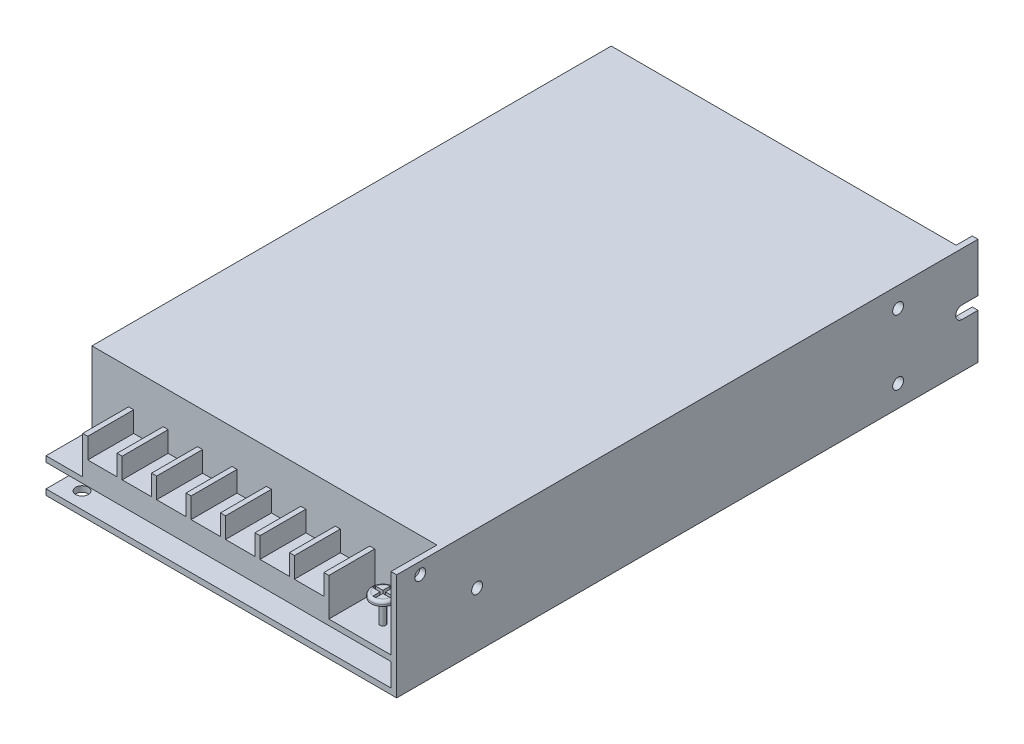
from build123d import *

# Parameters (mm, degrees)
SKETCH1_W           = 97
SKETCH1_H           = 29.491999944
BOSS_EXTRUDE1_DEPTH = 160.778000008
SKETCH2_W           = 95.4125
SKETCH2_H           = 6.35
CUT_EXTRUDE1_DEPTH  = 12.7
CUT_EXTRUDE2_DEPTH  = 19.967
SKETCH4_R           = 3.175
SKETCH4_R_2         = 0.79375
CUT_EXTRUDE3_DEPTH  = 6.35
FILLET1_R           = 0.79375
CUT_EXTRUDE4_DEPTH  = 1.27
SKETCH6_W           = 10.16
SKETCH6_H           = 27.904499944
CUT_EXTRUDE6_DEPTH  = 4.445
SKETCH7_R           = 1.5
CUT_EXTRUDE7_DEPTH  = 6.35
SKETCH8_R           = 1
SKETCH8_R_2         = 1.75
CUT_EXTRUDE8_DEPTH  = 6.35
CUT_EXTRUDE9_DEPTH  = 95.4125


with BuildPart() as part:
    # Sketch1 → Boss-Extrude1 (new body)
    with BuildSketch(Plane.XY):
        with Locations((48.5, 14.745999972)):
            Rectangle(SKETCH1_W, SKETCH1_H)
    extrude(amount=-BOSS_EXTRUDE1_DEPTH)

    # Sketch2 → Cut-Extrude1 (cut)
    with BuildSketch(Plane.XY):
        Polygon((95.4125, 9.525), (95.4125, 29.491999944), (0, 29.491999944), (0, 9.525), (10.16, 9.525), (10.16, 19.966999944), (11.557, 19.966999944), (11.557, 14.2875), (19.685, 14.2875), (19.685, 19.966999944), (21.082, 19.966999944), (21.082, 14.2875), (29.21, 14.2875), (29.21, 19.966999944), (30.607, 19.966999944), (30.607, 14.2875), (38.735, 14.2875), (38.735, 19.966999944), (40.132, 19.966999944), (40.132, 14.2875), (48.26, 14.2875), (48.26, 19.966999944), (49.657, 19.966999944), (49.657, 14.2875), (57.785, 14.2875), (57.785, 19.966999944), (59.182, 19.966999944), (59.182, 14.2875), (67.31, 14.2875), (67.31, 19.966999944), (68.707, 19.966999944), (68.707, 14.2875), (76.835, 14.2875), (76.835, 19.966999944), (78.232, 19.966999944), (78.232, 9.525), (83.64725, 9.525), (83.64725, 17.145), (89.99725, 17.145), (89.99725, 9.525), align=None)
        with Locations((47.70625, 4.7625)):
            Rectangle(SKETCH2_W, SKETCH2_H)
    extrude(amount=-CUT_EXTRUDE1_DEPTH, mode=Mode.SUBTRACT)

    # Sketch3 → Cut-Extrude2 (cut)
    with BuildSketch(Plane(origin=(0, 29.491999944, 0), x_dir=(1, 0, 0), z_dir=(0, 1, 0))):
        with BuildLine():
            ThreePointArc((89.99725, 6.35), (86.82225, 3.175), (83.64725, 6.35))
            Line((83.64725, 6.35), (83.64725, 0))
            Line((83.64725, 0), (89.99725, 0))
            Line((89.99725, 0), (89.99725, 6.35))
        make_face()
        with BuildLine():
            Line((89.99725, 12.7), (83.64725, 12.7))
            Line((83.64725, 12.7), (83.64725, 6.35))
            ThreePointArc((83.64725, 6.35), (86.82225, 9.525), (89.99725, 6.35))
            Line((89.99725, 6.35), (89.99725, 12.7))
        make_face()
    extrude(amount=-CUT_EXTRUDE2_DEPTH, mode=Mode.SUBTRACT)

    # Sketch4 → Cut-Extrude3 (cut)
    with BuildSketch(Plane(origin=(0, 9.525, 0), x_dir=(1, 0, 0), z_dir=(0, 1, 0))):
        with Locations((86.82225, 6.35)):
            Circle(SKETCH4_R)
        with Locations((86.82225, 6.35)):
            Circle(SKETCH4_R_2, mode=Mode.SUBTRACT)
    extrude(amount=CUT_EXTRUDE3_DEPTH, mode=Mode.SUBTRACT)

    # Fillet1
    fillet1_edges = [part.edges().sort_by_distance(p)[0] for p in [
        (83.64725, 17.145, -6.35),
    ]]
    fillet(fillet1_edges, radius=FILLET1_R)

    # Sketch5 → Cut-Extrude4 (cut)
    with BuildSketch(Plane(origin=(0, 17.145, 0), x_dir=(1, 0, 0), z_dir=(0, 1, 0))):
        Polygon((86.44125, 8.73125), (86.44125, 6.731), (84.441, 6.731), (84.441, 5.969), (86.44125, 5.969), (86.44125, 3.96875), (87.20325, 3.96875), (87.20325, 5.969), (89.2035, 5.969), (89.2035, 6.731), (87.20325, 6.731), (87.20325, 8.73125), align=None)
    extrude(amount=-CUT_EXTRUDE4_DEPTH, mode=Mode.SUBTRACT)

    # Sketch6 → Cut-Extrude6 (cut)
    with BuildSketch(Plane(origin=(0, 0, -160.778000008), x_dir=(-1, 0, 0), z_dir=(0, 0, -1))):
        with Locations((-90.3325, 15.539749972)):
            Rectangle(SKETCH6_W, SKETCH6_H)
    extrude(amount=-CUT_EXTRUDE6_DEPTH, mode=Mode.SUBTRACT)

    # Sketch7 → Cut-Extrude7 (cut)
    with BuildSketch(Plane(origin=(97, 0, 0), x_dir=(0, 0, -1), z_dir=(1, 0, 0))):
        with Locations((6.5024, 26.289)):
            Circle(SKETCH7_R)
        with Locations((22.225, 15.24)):
            Circle(SKETCH7_R)
        with Locations((138.684, 6)):
            Circle(SKETCH7_R)
        with Locations((138.684, 23.9832)):
            Circle(SKETCH7_R)
        with BuildLine():
            Line((160.778000008, 15.974), (156.3624, 15.974))
            ThreePointArc((156.3624, 15.974), (154.6124, 14.224), (156.3624, 12.474))
            Line((156.3624, 12.474), (160.778000008, 12.474))
            Line((160.778000008, 12.474), (160.778000008, 15.974))
        make_face()
    extrude(amount=-CUT_EXTRUDE7_DEPTH, mode=Mode.SUBTRACT)

    # Sketch8 → Cut-Extrude8 (cut)
    with BuildSketch(Plane.XZ):
        with Locations((65.25, -24.003)):
            Circle(SKETCH8_R)
        with Locations((65.25, -102.87)):
            Circle(SKETCH8_R)
        with Locations((5.461, -4.4958)):
            Circle(SKETCH8_R_2)
        with BuildLine():
            Line((92.146, -160.778000008), (92.146, -157.988))
            ThreePointArc((92.146, -157.988), (90.396, -156.238), (88.646, -157.988))
            Line((88.646, -157.988), (88.646, -160.778000008))
            Line((88.646, -160.778000008), (92.146, -160.778000008))
        make_face()
    extrude(amount=-CUT_EXTRUDE8_DEPTH, mode=Mode.SUBTRACT)

    # Sketch9 → Cut-Extrude9 (cut)
    with BuildSketch(Plane.ZY):
        Polygon((-160.778000008, 7.874), (-156.333000008, 12.319), (-156.333000008, 29.491999944), (-160.778000008, 29.491999944), align=None)
    extrude(amount=-CUT_EXTRUDE9_DEPTH, mode=Mode.SUBTRACT)


solid = part.part
